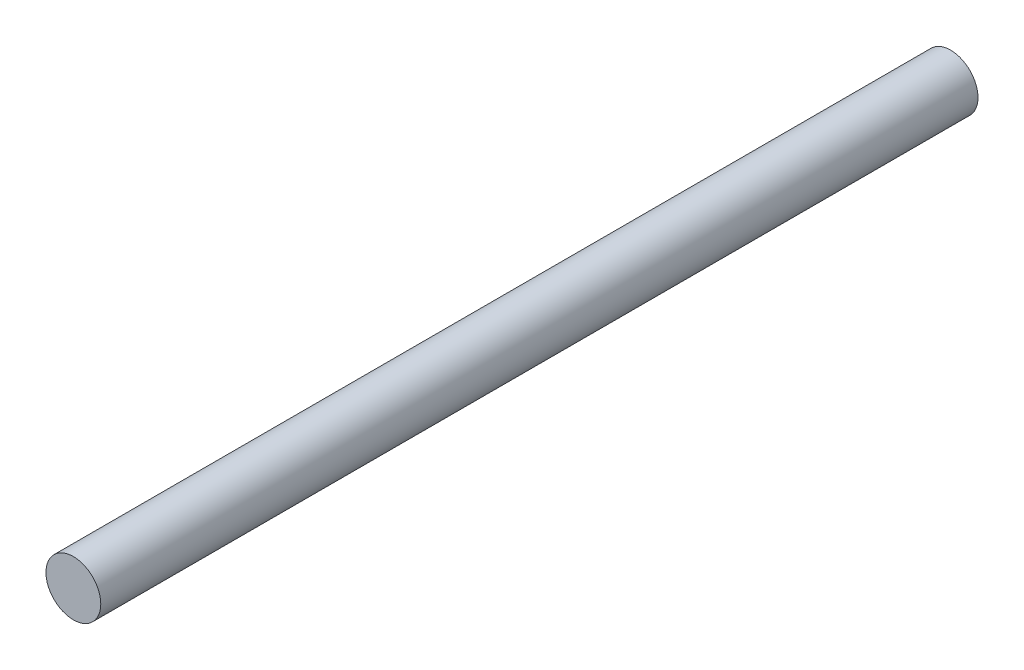
from build123d import *

# Parameters (mm, degrees)
SKETCH1_R           = 2.38125
BOSS_EXTRUDE1_DEPTH = 38.1


with BuildPart() as part:
    # Sketch1 → Boss-Extrude1 (new body, symmetric)
    with BuildSketch(Plane.XY):
        Circle(SKETCH1_R)
    extrude(amount=BOSS_EXTRUDE1_DEPTH, both=True)


solid = part.part
